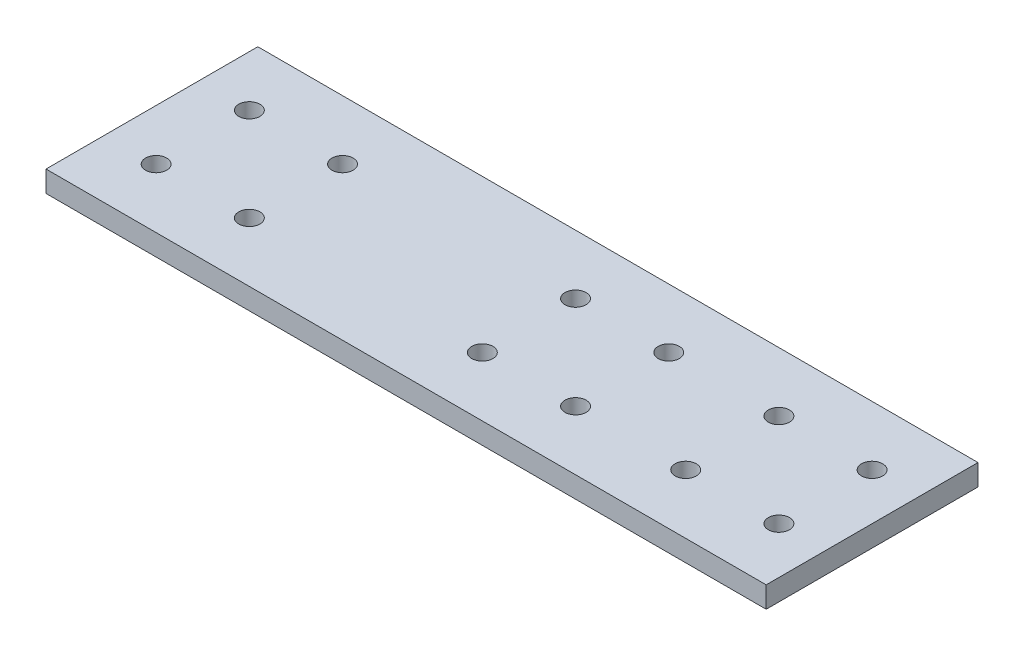
from build123d import *

# Parameters (mm, degrees)
SKETCH1_W           = 170
SKETCH1_H           = 50
SKETCH1_R           = 2.5
BOSS_EXTRUDE1_DEPTH = 5


with BuildPart() as part:
    # Sketch1 → Boss-Extrude1 (new body)
    with BuildSketch(Plane(origin=(0, 0, 0), x_dir=(1, 0, 0), z_dir=(0, 1, 0))):
        Rectangle(SKETCH1_W, SKETCH1_H)
        with Locations((74, 11)):
            Circle(SKETCH1_R, mode=Mode.SUBTRACT)
        with Locations((52, 11)):
            Circle(SKETCH1_R, mode=Mode.SUBTRACT)
        with Locations((52, -11)):
            Circle(SKETCH1_R, mode=Mode.SUBTRACT)
        with Locations((74, -11)):
            Circle(SKETCH1_R, mode=Mode.SUBTRACT)
        with Locations((26, 11)):
            Circle(SKETCH1_R, mode=Mode.SUBTRACT)
        with Locations((4, 11)):
            Circle(SKETCH1_R, mode=Mode.SUBTRACT)
        with Locations((4, -11)):
            Circle(SKETCH1_R, mode=Mode.SUBTRACT)
        with Locations((26, -11)):
            Circle(SKETCH1_R, mode=Mode.SUBTRACT)
        with Locations((-51, 11)):
            Circle(SKETCH1_R, mode=Mode.SUBTRACT)
        with Locations((-73, 11)):
            Circle(SKETCH1_R, mode=Mode.SUBTRACT)
        with Locations((-51, -11)):
            Circle(SKETCH1_R, mode=Mode.SUBTRACT)
        with Locations((-73, -11)):
            Circle(SKETCH1_R, mode=Mode.SUBTRACT)
    extrude(amount=BOSS_EXTRUDE1_DEPTH)


solid = part.part
